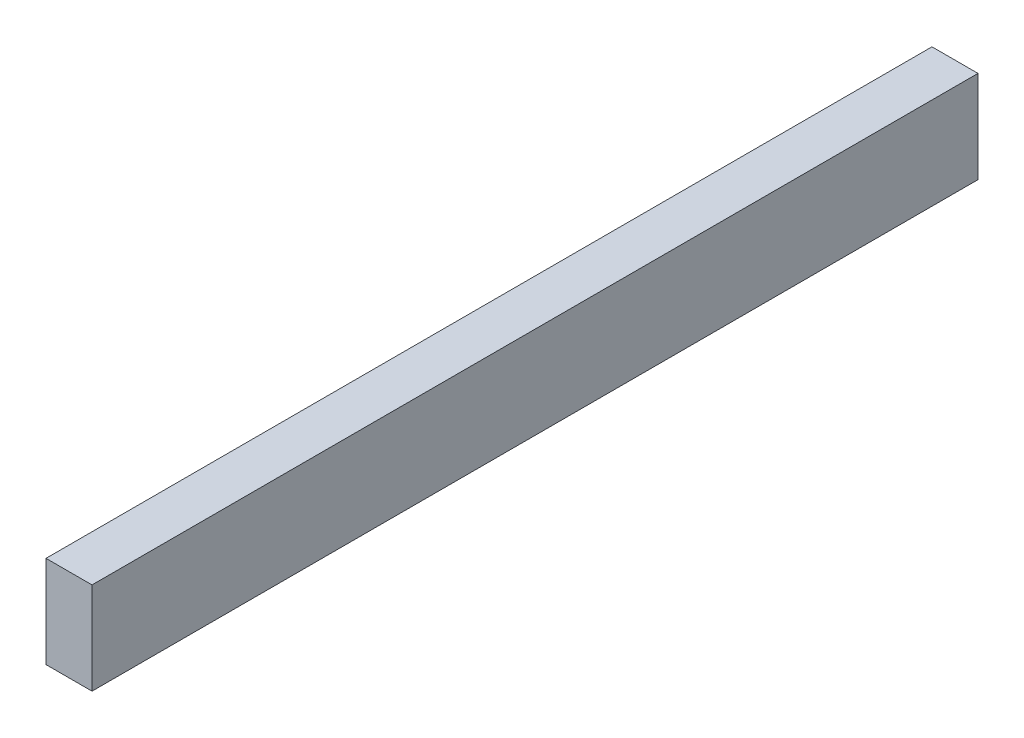
from build123d import *

# Parameters (mm, degrees)
SKETCH1_W           = 19.05
SKETCH1_H           = 38.1
BOSS_EXTRUDE1_DEPTH = 366.7125


with BuildPart() as part:
    # Sketch1 → Boss-Extrude1 (new body)
    with BuildSketch(Plane.XY):
        with Locations((9.525, 19.05)):
            Rectangle(SKETCH1_W, SKETCH1_H)
    extrude(amount=BOSS_EXTRUDE1_DEPTH)


solid = part.part
